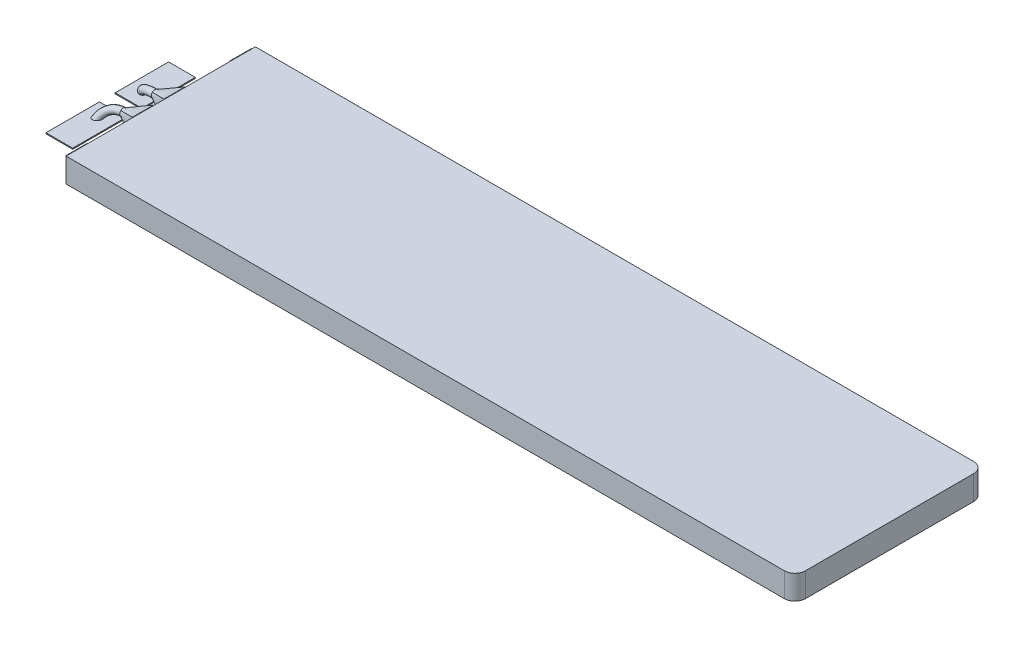
from build123d import *

# Parameters (mm, degrees)
BOSS_EXTRUDE1_DEPTH = 2.3
SKETCH2_W           = 2
SKETCH2_H           = 2
BOSS_EXTRUDE2_DEPTH = 0.2
SKETCH6_W           = 2
SKETCH6_H           = 2
SKETCH4_R           = 0.34
SKETCH7_W           = 2.54
SKETCH7_H           = 5.08
BOSS_EXTRUDE3_DEPTH = 0.1


with BuildPart() as part:
    # Sketch1 → Boss-Extrude1 (new body)
    with BuildSketch(Plane(origin=(0, 0, 0), x_dir=(1, 0, 0), z_dir=(0, 1, 0))):
        with BuildLine():
            Line((-34.65, 9), (33.65, 9))
            ThreePointArc((33.65, 9), (34.357106781, 8.707106781), (34.65, 8))
            Line((34.65, 8), (34.65, -8))
            ThreePointArc((34.65, -8), (34.357106781, -8.707106781), (33.65, -9))
            Line((33.65, -9), (-34.65, -9))
            Line((-34.65, -9), (-34.65, 9))
        make_face()
    extrude(amount=BOSS_EXTRUDE1_DEPTH)

    # Sketch2 → Boss-Extrude2 (add)
    with BuildSketch(Plane.ZY.offset(34.65)):
        with Locations((-7.8, 1.15)):
            Rectangle(SKETCH2_W, SKETCH2_H)
        with Locations((-1.5, 1.15)):
            Rectangle(SKETCH2_W, SKETCH2_H)
        with Locations((1.5, 1.15)):
            Rectangle(SKETCH2_W, SKETCH2_H)
        with Locations((7.8, 1.15)):
            Rectangle(SKETCH2_W, SKETCH2_H)
    extrude(amount=BOSS_EXTRUDE2_DEPTH)

    # Sketch6 → Loft1 section 0
    with BuildSketch(Plane.ZY.offset(34.85)):
        with Locations((-1.5, 1.15)):
            Rectangle(SKETCH6_W, SKETCH6_H)
    # Sketch5 for Loft1 → Loft1 section 1
    with BuildSketch(Plane(origin=(-36.709589787, 1.15, -1.5), x_dir=(0, 0, 1), z_dir=(-1, 0, 0))):
        with BuildLine():
            # circular arc as an exact rational Bezier (weights 1, cos(half-angle), 1)
            Bezier((-0.240416306, 0.240416306), (0, 0.48083261), (0.240416306, 0.240416306), weights=[1, 0.707106784, 1])
            Bezier((0.240416306, 0.240416306), (0.48083261, 0), (0.240416306, -0.240416306), weights=[1, 0.707106784, 1])
            Bezier((0.240416306, -0.240416306), (0, -0.48083261), (-0.240416306, -0.240416306), weights=[1, 0.707106784, 1])
            Bezier((-0.240416306, -0.240416306), (-0.48083261, 0), (-0.240416306, 0.240416306), weights=[1, 0.707106784, 1])
        make_face()
    loft1 = loft()

    # Sweep2: sweep along a curve in space
    with BuildLine() as sweep2_path:
        Line((-34.85, 1.15, -1.5), (-36.709589787, 1.15, -1.5))
        ThreePointArc((-36.709589787, 1.15, -1.5), (-38.088738075, 0.666726189, -1.804608948), (-38.66, -0.5, -2.54))
    # Sketch4 → Sweep2 (sweep)
    with BuildSketch(Plane.ZY.offset(34.85)):
        with Locations((-1.5, 1.15)):
            Circle(SKETCH4_R)
    sweep2 = sweep(path=sweep2_path.line)

    # Mirror4: Loft1, Sweep2 across plane
    add(loft1.mirror(Plane.XY))
    add(sweep2.mirror(Plane.XY))

    # Sketch7 → Boss-Extrude3 (add)
    with BuildSketch(Plane(origin=(0, 0, 0), x_dir=(1, 0, 0), z_dir=(0, 1, 0))):
        with Locations((-38.46, 3.29)):
            Rectangle(SKETCH7_W, SKETCH7_H)
        with Locations((-38.46, -3.29)):
            Rectangle(SKETCH7_W, SKETCH7_H)
    extrude(amount=BOSS_EXTRUDE3_DEPTH)


solid = part.part
